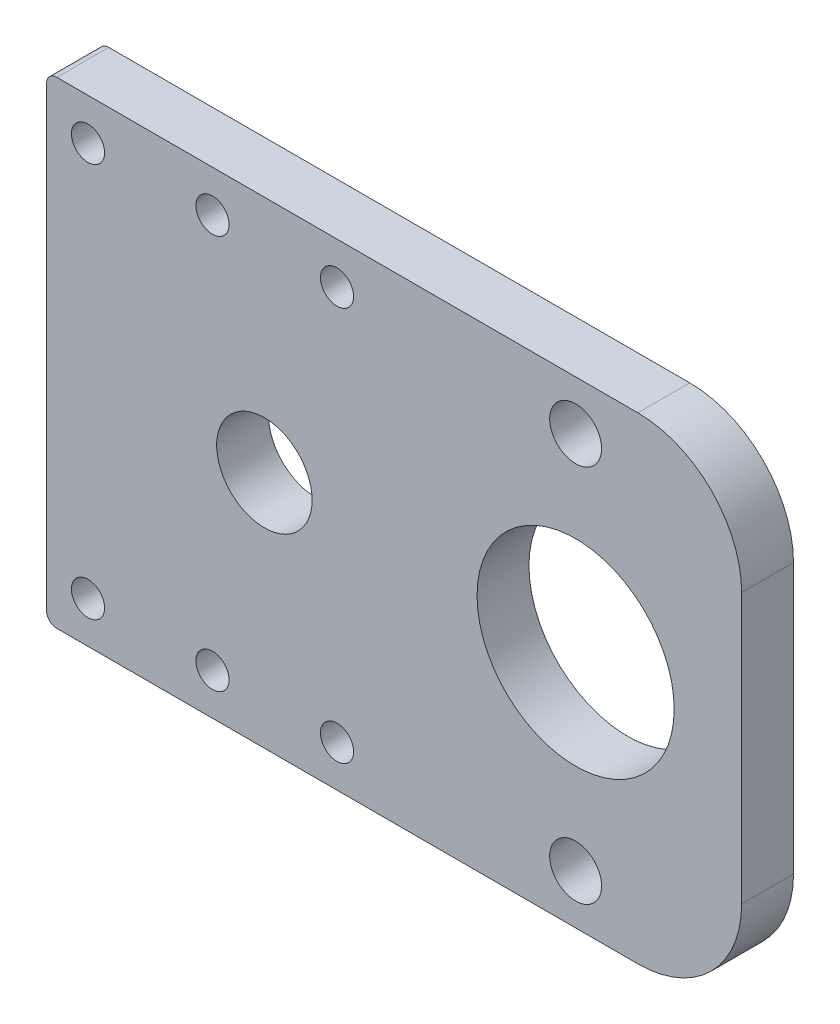
from build123d import *

# Parameters (mm, degrees)
SKETCH1_W           = 65
SKETCH1_H           = 46
SKETCH1_R           = 4.6
SKETCH1_R_2         = 2.5
BOSS_EXTRUDE1_DEPTH = 5
SKETCH2_R           = 1.6
CUT_EXTRUDE1_DEPTH  = 10
SKETCH3_W           = 4
SKETCH3_H           = 46
CUT_EXTRUDE2_DEPTH  = 6
SKETCH4_W           = 6
SKETCH4_H           = 46
BOSS_EXTRUDE2_DEPTH = 5
FILLET1_R           = 10
FILLET2_R           = 1


with BuildPart() as part:
    # Sketch1 → Boss-Extrude1 (new body)
    with BuildSketch(Plane.XY):
        with Locations((7.5, 0)):
            Rectangle(SKETCH1_W, SKETCH1_H)
        Circle(SKETCH1_R, mode=Mode.SUBTRACT)
        with Locations((30, -18.25)):
            Circle(SKETCH1_R_2, mode=Mode.SUBTRACT)
        with BuildLine():
            ThreePointArc((39.5, 0), (23.282485579, -6.717514421), (30, 9.5))
            ThreePointArc((30, 9.5), (36.717514421, 6.717514421), (39.5, 0))
        make_face(mode=Mode.SUBTRACT)
        with BuildLine():
            ThreePointArc((32.5, 18.25), (31.767766953, 16.482233047), (30, 15.75))
            ThreePointArc((30, 15.75), (28.232233047, 20.017766953), (32.5, 18.25))
        make_face(mode=Mode.SUBTRACT)
    extrude(amount=BOSS_EXTRUDE1_DEPTH)

    # Sketch2 → Cut-Extrude1 (cut)
    with BuildSketch(Plane.XY.offset(5)):
        with Locations((7, 19)):
            Circle(SKETCH2_R)
        with Locations((-5, -19)):
            Circle(SKETCH2_R)
        with Locations((-17, 19)):
            Circle(SKETCH2_R)
        with Locations((-5, 19)):
            Circle(SKETCH2_R)
        with Locations((7, -19)):
            Circle(SKETCH2_R)
        with Locations((-17, -19)):
            Circle(SKETCH2_R)
    extrude(amount=-CUT_EXTRUDE1_DEPTH, mode=Mode.SUBTRACT)

    # Sketch3 → Cut-Extrude2 (cut, through all)
    with BuildSketch(Plane.XY.offset(5)):
        with Locations((-23, 0)):
            Rectangle(SKETCH3_W, SKETCH3_H)
    extrude(amount=-CUT_EXTRUDE2_DEPTH, mode=Mode.SUBTRACT)

    # Sketch4 → Boss-Extrude2 (add)
    with BuildSketch(Plane.XY.offset(5)):
        with Locations((43, 0)):
            Rectangle(SKETCH4_W, SKETCH4_H)
    extrude(amount=-BOSS_EXTRUDE2_DEPTH)

    # Fillet1
    fillet1_edges = [part.edges().sort_by_distance(p)[0] for p in [
        (46, -23, 2.5),
        (46, 23, 2.5),
    ]]
    fillet(fillet1_edges, radius=FILLET1_R)

    # Fillet2
    fillet2_edges = [part.edges().sort_by_distance(p)[0] for p in [
        (-21, 23, 2.5),
        (-21, -23, 2.5),
    ]]
    fillet(fillet2_edges, radius=FILLET2_R)


solid = part.part
